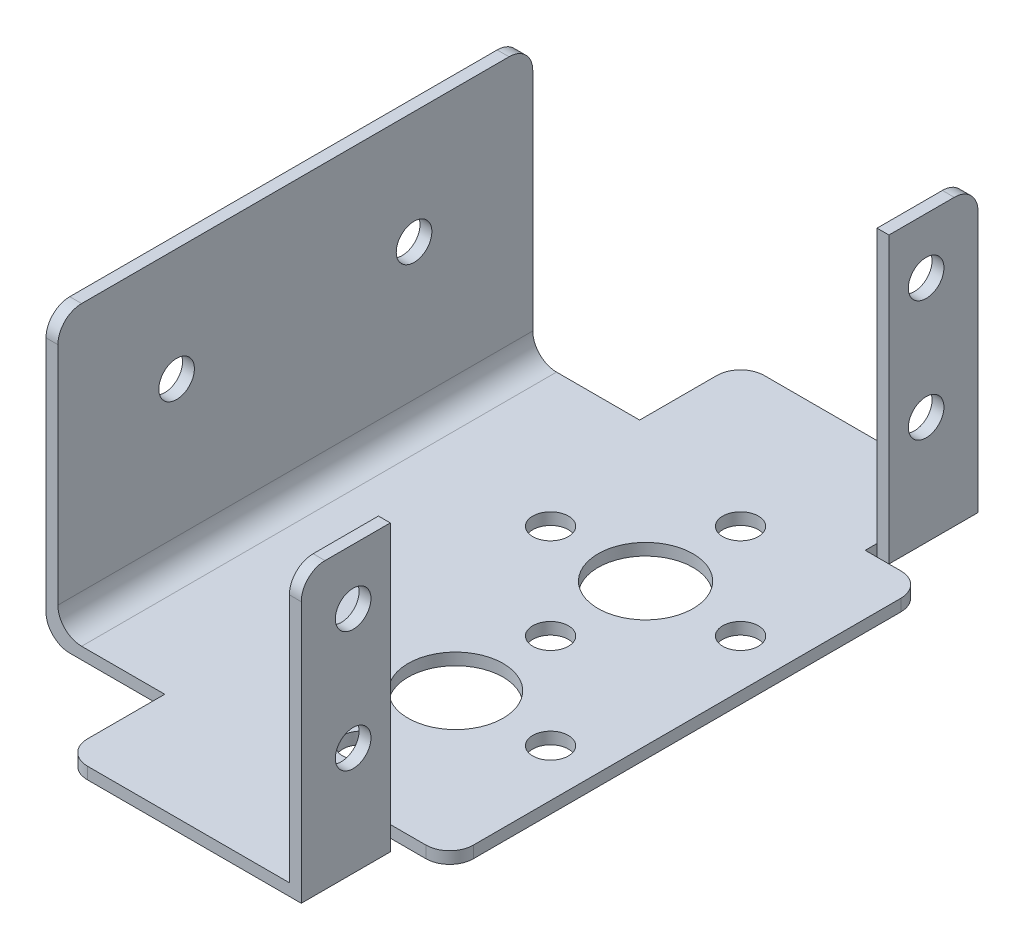
from build123d import *

# Parameters (mm, degrees)
BOSS_EXTRUDE1_DEPTH = 57
SKETCH2_W           = 42
SKETCH2_H           = 24
CUT_EXTRUDE1_DEPTH  = 1
SKETCH3_R           = 1.5
CUT_EXTRUDE2_DEPTH  = 2.54
SKETCH4_W           = 8.5
SKETCH4_H           = 24
CUT_EXTRUDE3_DEPTH  = 10
SKETCH5_R           = 1.5
CUT_EXTRUDE4_DEPTH  = 10
SKETCH6_W           = 40
SKETCH6_H           = 1
BOSS_EXTRUDE2_DEPTH = 5
SKETCH7_R           = 4
SKETCH7_R_2         = 1.5
CUT_EXTRUDE5_DEPTH  = 1
FILLET1_R           = 2


with BuildPart() as part:
    # Sketch1 → Boss-Extrude1 (new body)
    with BuildSketch(Plane.XY):
        Polygon((-46.692941858, 15.875), (-46.692941858, -8.125), (-16.692941858, -8.125), (-16.692941858, 15.875), (-17.692941858, 15.875), (-17.692941858, -7.125), (-45.692941858, -7.125), (-45.692941858, 15.875), align=None)
    extrude(amount=BOSS_EXTRUDE1_DEPTH)

    # Sketch2 → Cut-Extrude1 (cut)
    with BuildSketch(Plane(origin=(-16.692941858, 0, 0), x_dir=(0, 0, -1), z_dir=(1, 0, 0))):
        with Locations((-28.5, 3.875)):
            Rectangle(SKETCH2_W, SKETCH2_H)
    extrude(amount=-CUT_EXTRUDE1_DEPTH, mode=Mode.SUBTRACT)

    # Sketch3 → Cut-Extrude2 (cut)
    with BuildSketch(Plane(origin=(-16.692941858, 0, 0), x_dir=(0, 0, -1), z_dir=(1, 0, 0))):
        with Locations((-52.63, 11.176)):
            Circle(SKETCH3_R)
        with Locations((-4.37, 11.176)):
            Circle(SKETCH3_R)
        with Locations((-4.37, 1.016)):
            Circle(SKETCH3_R)
        with Locations((-52.63, 1.016)):
            Circle(SKETCH3_R)
    extrude(amount=-CUT_EXTRUDE2_DEPTH, mode=Mode.SUBTRACT)

    # Sketch4 → Cut-Extrude3 (cut)
    with BuildSketch(Plane.ZY.offset(46.692941858)):
        with Locations((4.25, 3.875)):
            Rectangle(SKETCH4_W, SKETCH4_H)
        with Locations((52.75, 3.875)):
            Rectangle(SKETCH4_W, SKETCH4_H)
    extrude(amount=-CUT_EXTRUDE3_DEPTH, mode=Mode.SUBTRACT)

    # Sketch5 → Cut-Extrude4 (cut)
    with BuildSketch(Plane.ZY.offset(46.692941858)):
        with Locations((38.5, 6.375)):
            Circle(SKETCH5_R)
        with Locations((18.5, 6.375)):
            Circle(SKETCH5_R)
    extrude(amount=-CUT_EXTRUDE4_DEPTH, mode=Mode.SUBTRACT)

    # Sketch6 → Boss-Extrude2 (add)
    with BuildSketch(Plane(origin=(-17.692941858, 0, 0), x_dir=(0, 0, -1), z_dir=(1, 0, 0))):
        with Locations((-28.5, -7.625)):
            Rectangle(SKETCH6_W, SKETCH6_H)
    extrude(amount=BOSS_EXTRUDE2_DEPTH)

    # Sketch7 → Cut-Extrude5 (cut)
    with BuildSketch(Plane(origin=(0, -8.125, 0), x_dir=(-1, 0, 0), z_dir=(0, -1, 0))):
        with Locations((24.692941858, -20)):
            Circle(SKETCH7_R)
        with Locations((24.692941858, -12)):
            Circle(SKETCH7_R_2)
        with Locations((32.692941858, -20)):
            Circle(SKETCH7_R_2)
        with Locations((24.692941858, -28)):
            Circle(SKETCH7_R_2)
        with Locations((16.692941858, -20)):
            Circle(SKETCH7_R_2)
        with Locations((32.692941858, -36)):
            Circle(SKETCH7_R_2)
        with Locations((24.692941858, -44)):
            Circle(SKETCH7_R_2)
        with Locations((16.692941858, -36)):
            Circle(SKETCH7_R_2)
        with Locations((24.692941858, -36)):
            Circle(SKETCH7_R)
    extrude(amount=-CUT_EXTRUDE5_DEPTH, mode=Mode.SUBTRACT)

    # Fillet1
    fillet1_edges = [part.edges().sort_by_distance(p)[0] for p in [
        (-12.692941858, -7.625, 8.5),
        (-12.692941858, -7.625, 48.5),
        (-17.192941858, 15.875, 57),
        (-36.692941858, -7.625, 0),
        (-46.192941858, 15.875, 8.5),
        (-45.692941858, -7.125, 28.5),
        (-46.692941858, -8.125, 28.5),
        (-36.692941858, -7.625, 57),
        (-17.192941858, 15.875, 0),
        (-46.192941858, 15.875, 48.5),
    ]]
    fillet(fillet1_edges, radius=FILLET1_R)


solid = part.part
